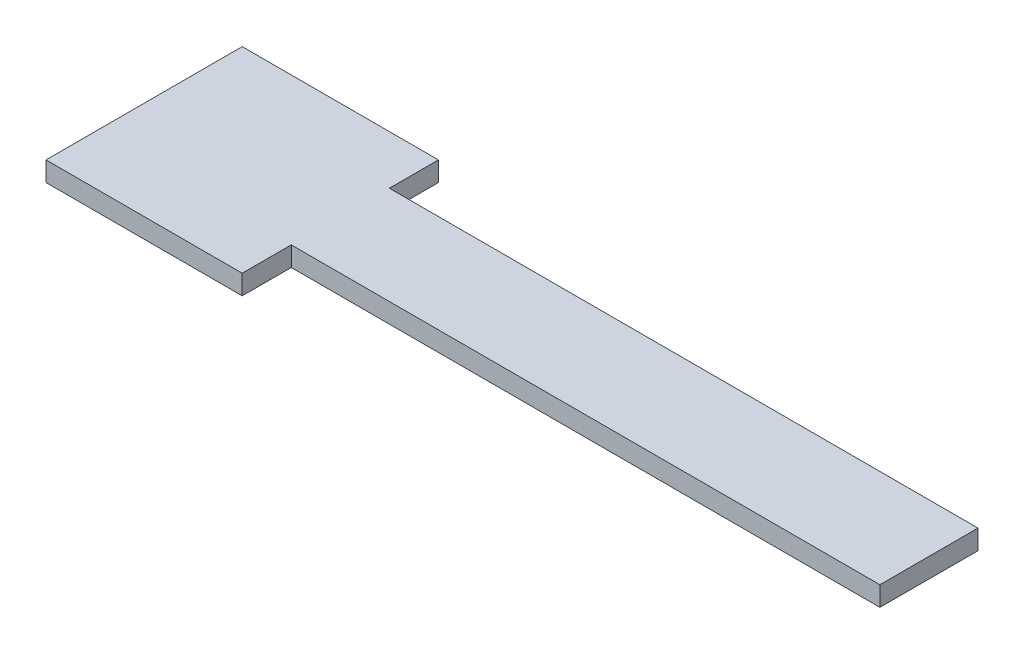
from build123d import *

# Parameters (mm, degrees)
SKETCH1_W      = 60
SKETCH1_H      = 10
EXTRUDE1_DEPTH = 2
SKETCH2_W      = 20
SKETCH2_H      = 20
EXTRUDE2_DEPTH = 2


with BuildPart() as part:
    # Sketch1 → Extrude1 (new body)
    with BuildSketch(Plane(origin=(0, 0, 0), x_dir=(1, 0, 0), z_dir=(0, 1, 0))):
        with Locations((30, 5)):
            Rectangle(SKETCH1_W, SKETCH1_H)
    extrude(amount=EXTRUDE1_DEPTH)

    # Sketch2 → Extrude2 (add)
    with BuildSketch(Plane(origin=(0, 2, 0), x_dir=(-1, 0, 0), z_dir=(0, 1, 0))):
        with Locations((10, -5)):
            Rectangle(SKETCH2_W, SKETCH2_H)
    extrude(amount=-EXTRUDE2_DEPTH)


solid = part.part
